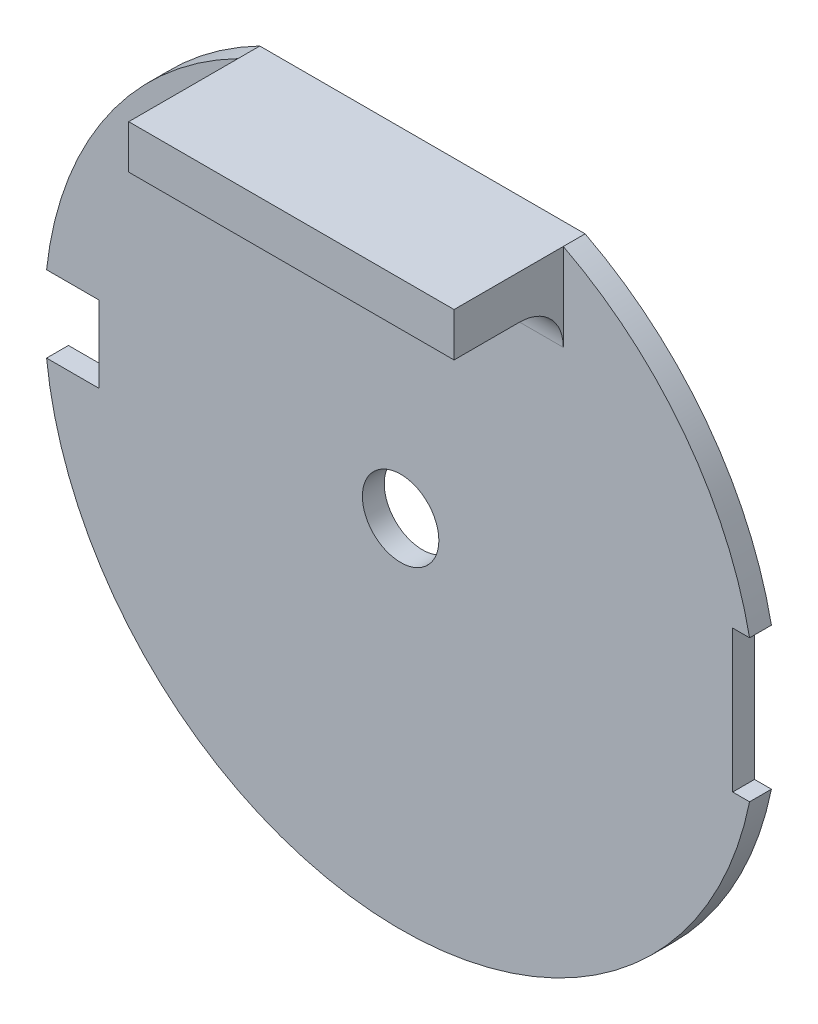
from build123d import *

# Parameters (mm, degrees)
SKETCH_1_R          = 1.75
EXTRUDE_1_DEPTH     = 1
SKETCH_2_W          = 5
SKETCH_2_H          = 3.5
SKETCH_2_W_2        = 2
SKETCH_2_H_2        = 6.5
CUT_EXTRUDE_1_DEPTH = 2
SKETCH_3_W          = 14.891608376
SKETCH_3_H          = 2
EXTRUDE_2_DEPTH     = 5
FILLET_1_R          = 2


with BuildPart() as part:
    # 草图1 → 凸台-拉伸1 (new body)
    with BuildSketch(Plane.XY):
        with BuildLine():
            Line((-7.445804188, 14.5), (7.445804188, 14.5))
            ThreePointArc((7.445804188, 14.5), (0, -16.3), (-7.445804188, 14.5))
        make_face()
        Circle(SKETCH_1_R, mode=Mode.SUBTRACT)
    extrude(amount=EXTRUDE_1_DEPTH)

    # 草图2 → 切除-拉伸1 (cut, through all)
    with BuildSketch(Plane.XY.offset(1)):
        with Locations((-16.3, 0)):
            Rectangle(SKETCH_2_W, SKETCH_2_H)
        with Locations((16.2, 0)):
            Rectangle(SKETCH_2_W_2, SKETCH_2_H_2)
    extrude(amount=-CUT_EXTRUDE_1_DEPTH, mode=Mode.SUBTRACT)

    # 草图3 → 凸台-拉伸2 (add)
    with BuildSketch(Plane.XY.offset(1)):
        with Locations((0, 13.5)):
            Rectangle(SKETCH_3_W, SKETCH_3_H)
    extrude(amount=EXTRUDE_2_DEPTH)

    # 圆角1
    fillet_1_edges = [part.edges().sort_by_distance(p)[0] for p in [
        (0, 12.5, 1),
    ]]
    fillet(fillet_1_edges, radius=FILLET_1_R)


solid = part.part
